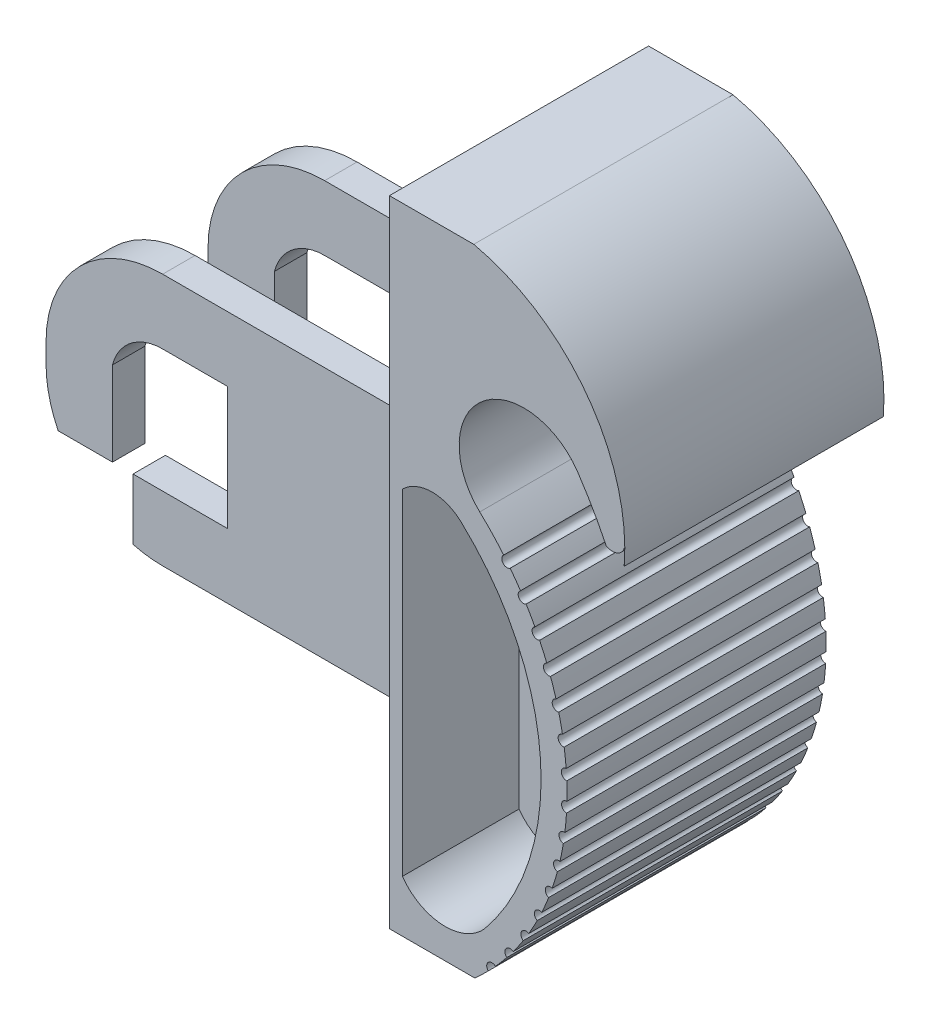
from build123d import *

# Parameters (mm, degrees)
CROQUIS1_W              = 30
CROQUIS1_H              = 49
SALIENTE_EXTRUIR1_DEPTH = 20
CORTAR_EXTRUIR3_DEPTH   = 20
CORTAR_EXTRUIR5_DEPTH   = 20
CORTAR_EXTRUIR6_DEPTH   = 0.3
CROQUIS5_W              = 13.233735145
CROQUIS5_H              = 2.403316153
CORTAR_EXTRUIR9_DEPTH   = 20.3
CROQUIS6_W              = 2.5
CROQUIS6_H              = 19.5
SALIENTE_EXTRUIR2_DEPTH = 29
REDONDEO1_R             = 9
CORTAR_EXTRUIR10_DEPTH  = 29
CORTAR_EXTRUIR11_DEPTH  = 29
CORTAR_EXTRUIR16_DEPTH  = 9
CORTAR_EXTRUIR17_START  = -2
CORTAR_EXTRUIR17_DEPTH  = 9
CROQUIS13_R             = 0.40141899
CORTAR_EXTRUIR18_DEPTH  = 22
MATRIZC1_COUNT          = 15
MATRIZC1_ANGLE          = 82


with BuildPart() as part:
    # Croquis1 → Saliente-Extruir1 (new body)
    with BuildSketch(Plane.XY):
        Rectangle(CROQUIS1_W, CROQUIS1_H)
    extrude(amount=SALIENTE_EXTRUIR1_DEPTH)

    # Croquis2 → Cortar-Extruir3 (cut)
    with BuildSketch(Plane.XY.offset(20)):
        with BuildLine():
            ThreePointArc((-0.474525342, 13.297985817), (-5.593414892, 15.404003131), (-9.517328589, 11.5))
            ThreePointArc((-9.517328589, 11.5), (-9.593029868, 11.00254481), (-9.618349103, 10.5))
            ThreePointArc((-9.618349103, 10.5), (-9.39256168, 9.014438062), (-8.735591395, 7.663044605))
            ThreePointArc((-8.735591395, 7.663044605), (-8.404944841, 7.234775243), (-8.029958496, 6.84474059))
            ThreePointArc((-8.029958496, 6.84474059), (-5.140673383, 3.522596276), (-3, -0.324757201))
            ThreePointArc((-3, -0.324757201), (-1.808741917, -13.286004066), (-8.416261219, -24.5))
            Line((-8.416261219, -24.5), (15, -24.5))
            Line((15, -24.5), (15, 24.5))
            Line((15, 24.5), (-8.489066238, 24.5))
            ThreePointArc((-8.489066238, 24.5), (0.804926071, 18.001388169), (2.839493239, 6.84474059))
            ThreePointArc((2.839493239, 6.84474059), (1.375466316, 10.170467938), (-0.474525342, 13.297985817))
        make_face()
    extrude(amount=-CORTAR_EXTRUIR3_DEPTH, mode=Mode.SUBTRACT)

    # Croquis3 → Cortar-Extruir5 (cut)
    with BuildSketch(Plane.XY.offset(20)):
        with BuildLine():
            Line((3.120918342, 8.787733578), (3.139240721, 10.044961504))
            ThreePointArc((3.139240721, 10.044961504), (2.537101628, 9.384743505), (1.652711167, 9.512465101))
            Line((1.652711167, 9.512465101), (2.839493239, 6.84474059))
            Line((2.839493239, 6.84474059), (3.120918342, 8.787733578))
        make_face()
    extrude(amount=-CORTAR_EXTRUIR5_DEPTH, mode=Mode.SUBTRACT)

    # Croquis4 → Cortar-Extruir6 (cut)
    with BuildSketch(Plane(origin=(2.992213613, -0.043607425, 0), x_dir=(0, 0, 1), z_dir=(-0.999893822, 0.014572086, 0))):
        Polygon((19.964912912, 10.079116377), (20.184817926, 6.981498966), (0, 6.981498966), (0, 10.089640231), align=None)
    extrude(amount=CORTAR_EXTRUIR6_DEPTH, mode=Mode.SUBTRACT)

    # Croquis5 → Cortar-Extruir9 (cut)
    with BuildSketch(Plane(origin=(2.853385744, 6.940656131, 20), x_dir=(-1, 0, 0), z_dir=(0, 0, -1))):
        with Locations((-6.558491356, -0.917958816)):
            Rectangle(CROQUIS5_W, CROQUIS5_H)
    extrude(amount=CORTAR_EXTRUIR9_DEPTH, mode=Mode.SUBTRACT)

    # Croquis6 → Saliente-Extruir2 (add)
    with BuildSketch(Plane.ZY.offset(15)):
        with Locations((16.25, -1.75)):
            Rectangle(CROQUIS6_W, CROQUIS6_H)
        with Locations((3.75, -1.75)):
            Rectangle(CROQUIS6_W, CROQUIS6_H)
    extrude(amount=SALIENTE_EXTRUIR2_DEPTH)

    # Redondeo1
    redondeo1_edges = [part.edges().sort_by_distance(p)[0] for p in [
        (-44, -11.5, 16.25),
        (-44, 8, 16.25),
        (-44, -11.5, 3.75),
        (-44, 8, 3.75),
    ]]
    fillet(redondeo1_edges, radius=REDONDEO1_R)

    # Croquis7 → Cortar-Extruir10 (cut)
    with BuildSketch(Plane(origin=(0, 0, 2.5), x_dir=(-1, 0, 0), z_dir=(0, 0, -1))):
        with BuildLine():
            Line((37.288140826, -6.5), (37.288140826, -11.204275476))
            ThreePointArc((37.288140826, -11.204275476), (38.094193196, -10.951388553), (38.872983346, -10.624038405))
            Line((38.872983346, -10.624038405), (38.872983346, 0))
            ThreePointArc((38.872983346, 0), (37.449489743, 2.16227766), (35, 3))
            Line((35, 3), (30, 3))
            Line((30, 3), (30, -6.5))
            Line((30, -6.5), (37.288140826, -6.5))
        make_face()
    extrude(amount=-CORTAR_EXTRUIR10_DEPTH, mode=Mode.SUBTRACT)

    # Croquis8 → Cortar-Extruir11 (cut)
    with BuildSketch(Plane(origin=(0, 0, 2.5), x_dir=(-1, 0, 0), z_dir=(0, 0, -1))):
        with BuildLine():
            Line((43.062257748, -6.5), (38.872983346, -6.5))
            Line((38.872983346, -6.5), (38.872983346, -10.624038405))
            ThreePointArc((38.872983346, -10.624038405), (41.313827539, -8.91370266), (43.062257748, -6.5))
        make_face()
    extrude(amount=-CORTAR_EXTRUIR11_DEPTH, mode=Mode.SUBTRACT)

    # Croquis9 → Cortar-Extruir16 (cut)
    with BuildSketch(Plane(origin=(0, 0, 0), x_dir=(-1, 0, 0), z_dir=(0, 0, -1))):
        with BuildLine():
            Line((14, -20.5), (14, 5.382636826))
            ThreePointArc((14, 5.382636826), (11.773893936, 6.335545077), (9.505438523, 5.488377807))
            ThreePointArc((9.505438523, 5.488377807), (9.450309647, 5.43520412), (9.394602253, 5.382636826))
            ThreePointArc((9.394602253, 5.382636826), (3.353377533, -7.168166886), (7.3883863, -20.5))
            ThreePointArc((7.3883863, -20.5), (7.528094247, -20.675980579), (7.669852324, -20.850313944))
            ThreePointArc((7.669852324, -20.850313944), (10.918883483, -22.192259689), (14, -20.5))
        make_face()
    extrude(amount=-CORTAR_EXTRUIR16_DEPTH, mode=Mode.SUBTRACT)

    # Croquis11 → Cortar-Extruir17 (cut)
    with BuildSketch(Plane(origin=(0, 0, 9), x_dir=(-1, 0, 0), z_dir=(0, 0, -1)).offset(CORTAR_EXTRUIR17_START)):
        with BuildLine():
            Line((14, -20.5), (14, 5.382636826))
            ThreePointArc((14, 5.382636826), (11.773893936, 6.335545077), (9.505438523, 5.488377807))
            ThreePointArc((9.505438523, 5.488377807), (9.450309647, 5.43520412), (9.394602253, 5.382636826))
            ThreePointArc((9.394602253, 5.382636826), (3.337324426, -7.392286881), (7.669852324, -20.850313944))
            ThreePointArc((7.669852324, -20.850313944), (10.918883483, -22.192259689), (14, -20.5))
        make_face()
    extrude(amount=-CORTAR_EXTRUIR17_DEPTH, mode=Mode.SUBTRACT)

    # Croquis13 → Cortar-Extruir18 (cut)
    with BuildSketch(Plane(origin=(0, 0, 0), x_dir=(-1, 0, 0), z_dir=(0, 0, -1))):
        with Locations((5.927972834, 4.573929347)):
            Circle(CROQUIS13_R)
    cortar_extruir18 = extrude(amount=-CORTAR_EXTRUIR18_DEPTH, mode=Mode.SUBTRACT)

    # MatrizC1: Cortar-Extruir18 ×15 about axis
    matrizc1_axis = Axis((-22.493499964, -8.651756801, 0), (0, 0, -1))
    for i in range(1, MATRIZC1_COUNT):
        add(cortar_extruir18.rotate(matrizc1_axis, i * MATRIZC1_ANGLE / (MATRIZC1_COUNT - 1)), mode=Mode.SUBTRACT)


solid = part.part
